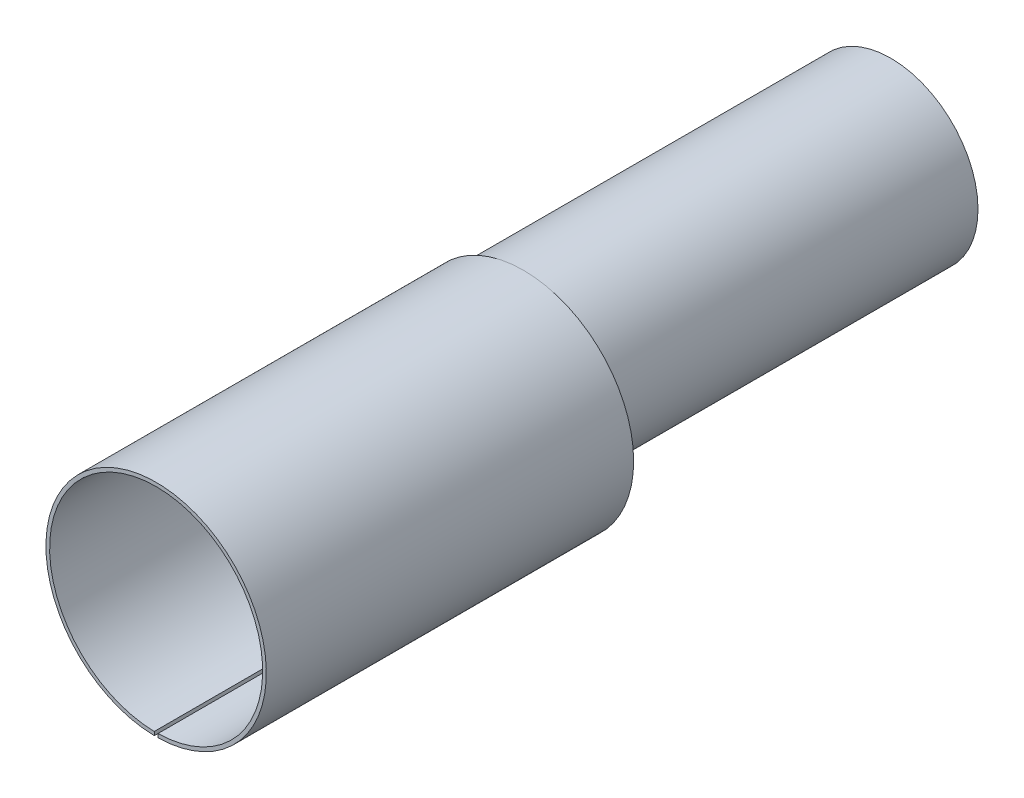
from build123d import *

# Parameters (mm, degrees)
SKIZZE1_R                            = 6
SKIZZE1_R_2                          = 5.8
AUFSATZ_LINEAR_AUSTRAGEN1_DEPTH      = 20
SKIZZE14_R                           = 4.75
SKIZZE14_R_2                         = 4.55
AUFSATZ_LINEAR_AUSTRAGEN2_DEPTH      = 20
SKIZZE13_W                           = 0.2
SKIZZE13_H                           = 6.257026497
SCHNITT_LINEAR_AUSTRAGEN3_DEPTH      = 20
SCHNITT_LINEAR_AUSTRAGEN3_DEPTH_BACK = 20


with BuildPart() as part:
    # Skizze1 → Aufsatz-Linear austragen1 (new body)
    with BuildSketch(Plane.XY):
        Circle(SKIZZE1_R)
        Circle(SKIZZE1_R_2, mode=Mode.SUBTRACT)
    extrude(amount=AUFSATZ_LINEAR_AUSTRAGEN1_DEPTH)

    # Skizze14 → Aufsatz-Linear austragen2 (add)
    with BuildSketch(Plane.XY):
        with Locations((0, 1.25)):
            Circle(SKIZZE14_R)
        with Locations((0, 1.25)):
            Circle(SKIZZE14_R_2, mode=Mode.SUBTRACT)
    extrude(amount=-AUFSATZ_LINEAR_AUSTRAGEN2_DEPTH)

    # Skizze13 → Schnitt-Linear austragen3 (cut, two sides)
    with BuildSketch(Plane.XY) as schnitt_linear_austragen3_sk:
        with Locations((0, -3.942046331)):
            Rectangle(SKIZZE13_W, SKIZZE13_H)
    extrude(amount=SCHNITT_LINEAR_AUSTRAGEN3_DEPTH, mode=Mode.SUBTRACT)
    extrude(schnitt_linear_austragen3_sk.sketch, amount=-SCHNITT_LINEAR_AUSTRAGEN3_DEPTH_BACK, mode=Mode.SUBTRACT)


solid = part.part
